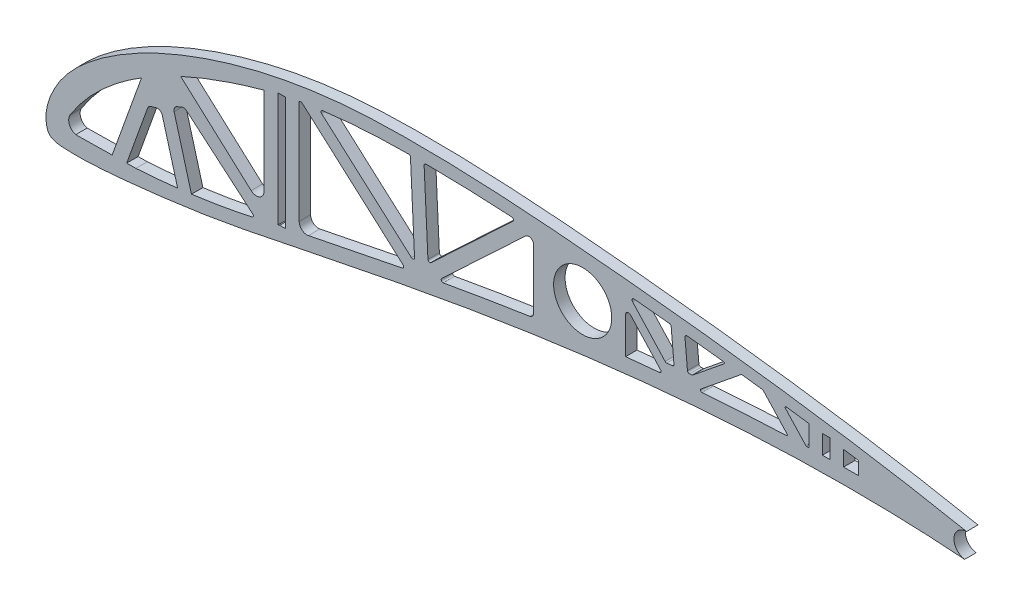
from build123d import *

# Parameters (mm, degrees)
BOSS_EXTRUDE1_DEPTH = 2.999994
CUT_EXTRUDE1_DEPTH  = 442.509045432


with BuildPart() as part:
    # Sketch5 → Boss-Extrude1 (new body)
    with BuildSketch(Plane.XY):
        with BuildLine():
            ThreePointArc((421.359482724, 115.899645077), (418.060296537, 112.846693401), (420.848691157, 109.321073047))
            add(Edge.make_bspline(
                [(421.359482724, 115.899645077), (419.422939988, 116.284255342), (414.228556348, 117.289659143), (405.625902382, 118.850738255), (395.429831787, 120.551182356), (384.871112955, 122.177527554), (374.010769017, 123.70780581), (362.918840653, 125.146254204), (351.666446869, 126.481244094), (340.335006422, 127.709125141), (329.014820288, 128.840925514), (317.799901282, 129.845464185), (306.781783127, 130.702319985), (296.038637416, 131.355846156), (285.63235588, 131.76410293), (275.621652199, 131.864898577), (266.057112324, 131.708674412), (256.959041301, 131.115735932), (248.324428285, 130.048336472), (240.116869122, 128.593792257), (232.33442802, 126.748456413), (224.983805263, 124.608842409), (218.095726105, 122.211484694), (211.698881932, 119.61063358), (205.83305294, 116.820298862), (200.516416551, 113.895751123), (195.777665531, 110.869813311), (191.646222096, 107.78301331), (188.122929029, 104.699592527), (185.259935993, 101.587133278), (183.070700685, 98.472434373), (181.463453667, 95.449399831), (180.446050206, 92.586133024), (179.978667249, 89.949794547), (180.106270294, 87.727234024), (180.706736606, 85.695404682), (182.848852115, 84.712029214), (185.712266238, 84.609143082), (189.628630725, 84.525044197), (194.54846024, 84.804700692), (200.418474116, 85.275220574), (207.172506559, 85.992641777), (214.741551325, 86.941862316), (223.08839502, 88.140518381), (232.206318165, 89.780943478), (242.140449319, 91.817484873), (252.943553217, 94.033776805), (264.563402805, 96.376783078), (276.928065981, 98.754869756), (289.947648613, 101.083910875), (303.52189838, 103.290712061), (317.534609223, 105.299544897), (331.860269168, 107.055783674), (346.364310587, 108.487545698), (360.901451873, 109.560734642), (375.320165522, 110.238690692), (389.464322211, 110.492986766), (403.176168896, 110.317339134), (413.589267576, 109.841826439), (419.410763405, 109.431625018), (420.848691157, 109.321073047)],
                knots=[0.106715339, 0.106715339, 0.106715339, 0.106715339, 0.115990637, 0.131570422, 0.147788379, 0.164550917, 0.181757895, 0.199311955, 0.217095072, 0.234990228, 0.252856883, 0.270540594, 0.287886779, 0.304773438, 0.321101419, 0.336806063, 0.351800033, 0.366031063, 0.379615675, 0.392652963, 0.405170359, 0.417171919, 0.428603517, 0.439418959, 0.449596586, 0.459102079, 0.467907878, 0.475988301, 0.483308969, 0.489874508, 0.49580325, 0.501149412, 0.505903073, 0.510046769, 0.513579311, 0.516446927, 0.519350053, 0.523823355, 0.529973794, 0.537715654, 0.546967844, 0.557637367, 0.569620481, 0.582804124, 0.597246961, 0.613135037, 0.6304436, 0.649056124, 0.668822257, 0.689594964, 0.711189651, 0.733426689, 0.756094118, 0.778988554, 0.801889683, 0.824566598, 0.846792285, 0.868338291, 0.888978163, 0.895752992, 0.895752992, 0.895752992, 0.895752992], degree=3))
        make_face()
    extrude(amount=BOSS_EXTRUDE1_DEPTH)

    # Sketch7 → Cut-Extrude1 (cut, through all)
    with BuildSketch(Plane.XY.offset(2.999994)):
        with BuildLine():
            Line((213.642245402, 107.343064385), (218.190281824, 90.885724053))
            add(Edge.make_bspline(
                [(218.190281824, 90.885724053), (223.54842124, 91.601696012), (228.883768537, 92.533835132), (234.204579075, 93.680780501)],
                knots=[0.606867129, 0.606867129, 0.606867129, 0.606867129, 0.897544008, 0.897544008, 0.897544008, 0.897544008], degree=3))
            ThreePointArc((234.204579075, 93.680780501), (234.412432502, 94.053617139), (234.243207207, 94.445501056))
            Line((234.243207207, 94.445501056), (232.954197496, 95.542398431))
            Line((232.954197496, 95.542398431), (216.91552149, 109.190690951))
            ThreePointArc((216.91552149, 109.190690951), (216.275180402, 109.480275071), (215.578889972, 109.385010658))
            Line((215.578889972, 109.385010658), (214.352783449, 108.842876386))
            ThreePointArc((214.352783449, 108.842876386), (213.718644606, 108.225085355), (213.642245402, 107.343064385))
        make_face()
        with BuildLine():
            Line((201.19969266, 89.439567272), (203.633260847, 89.477154123))
            add(Edge.make_bspline(
                [(203.633260847, 89.477154123), (207.290031523, 89.696995537), (210.932967113, 90.016308369), (214.564622737, 90.434671401)],
                knots=[0.344744583, 0.344744583, 0.344744583, 0.344744583, 0.541368109, 0.541368109, 0.541368109, 0.541368109], degree=3))
            Line((214.564622737, 90.434671401), (210.53930593, 105.000519713))
            ThreePointArc((210.53930593, 105.000519713), (209.941564564, 105.767018379), (208.976901187, 105.88634781))
            Line((208.976901187, 105.88634781), (207.552098501, 105.492599223))
            ThreePointArc((207.552098501, 105.492599223), (207.027161953, 105.200009948), (206.695522088, 104.698829479))
            Line((206.695522088, 104.698829479), (201.19969266, 89.439567272))
        make_face()
        with BuildLine():
            Line((187.845211094, 89.23330516), (197.398942173, 89.38086407))
            Line((197.398942173, 89.38086407), (205.097671742, 110.756515317))
            add(Edge.make_bspline(
                [(186.396762558, 93.028007776), (190.627378034, 99.747219914), (196.861014429, 105.656722428), (205.097671742, 110.756515317)],
                knots=[0.078395606, 0.078395606, 0.078395606, 0.078395606, 0.504900168, 0.504900168, 0.504900168, 0.504900168], degree=3))
            ThreePointArc((186.396762558, 93.028007776), (186.173187964, 90.768879008), (187.845211094, 89.23330516))
        make_face()
        with BuildLine():
            add(Edge.make_bspline(
                [(215.356082941, 116.219932627), (221.777396102, 119.170569876), (229.065901923, 121.770649506), (237.221600403, 124.020171518)],
                knots=[0.666985205, 0.666985205, 0.666985205, 0.666985205, 0.947618203, 0.947618203, 0.947618203, 0.947618203], degree=3))
            Line((215.356082941, 116.219932627), (233.827637739, 99.537260179))
            ThreePointArc((233.827637739, 99.537260179), (236.014680965, 99.188315304), (237.221600403, 101.045266049))
            Line((237.221600403, 101.045266049), (237.221600403, 110.844253218))
            Line((237.221600403, 110.844253218), (237.221600403, 124.020171518))
        make_face()
        with BuildLine():
            add(Edge.make_bspline(
                [(249.049624439, 96.863139544), (252.442739344, 97.564667818), (260.557528515, 99.233868378), (268.702010572, 100.849804318), (273.448389189, 101.758431722)],
                knots=[0.624761538, 0.624761538, 0.624761538, 0.624761538, 0.641030411, 0.66365445, 0.66365445, 0.66365445, 0.66365445], degree=3))
            ThreePointArc((273.448389189, 101.758431722), (273.807397327, 102.109530386), (273.66007194, 102.58958491))
            Line((273.66007194, 102.58958491), (247.219908667, 126.055673912))
            ThreePointArc((247.219908667, 126.055673912), (247.030859164, 126.159124951), (246.815628716, 126.169973273))
            add(Edge.make_bspline(
                [(246.815628716, 126.169973273), (246.845447128, 126.175845694), (246.875270404, 126.181690112)],
                knots=[0, 0, 0, 0.010414543, 0.010414543, 0.010414543], degree=2))
            add(Edge.make_bspline(
                [(246.875270404, 126.181690112), (246.723964627, 126.155930192), (246.572700448, 126.129938085), (246.421478436, 126.103713596)],
                knots=[1.383595085, 1.383595085, 1.383595085, 1.383595085, 1.38433327, 1.38433327, 1.38433327, 1.38433327], degree=3))
            Line((246.421478436, 126.103713596), (246.421478436, 110.844253218))
            Line((246.421478436, 110.844253218), (246.421478436, 98.814819418))
            ThreePointArc((246.421478436, 98.814819418), (247.17048458, 97.239081253), (248.865327613, 96.824994235))
            Line((248.865327613, 96.824994235), (249.049624439, 96.863139544))
        make_face()
        with BuildLine():
            add(Edge.make_bspline(
                [(275.105968573, 128.45257632), (275.11655477, 128.453053472), (275.127141067, 128.453526281)],
                knots=[0, 0, 0, 0.004656307, 0.004656307, 0.004656307], degree=2))
            add(Edge.make_bspline(
                [(275.127141067, 128.453526281), (273.34144729, 128.438772526), (268.404924317, 128.352568235), (260.863944067, 127.980339584), (255.124382119, 127.37601576), (252.500146594, 127.030357334)],
                knots=[1.338276177, 1.338276177, 1.338276177, 1.338276177, 1.346756394, 1.36175293, 1.374476832, 1.374476832, 1.374476832, 1.374476832], degree=3))
            add(Edge.make_bspline(
                [(252.500146594, 127.030357334), (252.543459431, 127.03496862), (252.586782222, 127.039522603)],
                knots=[0.985102215, 0.985102215, 0.985102215, 1, 1, 1], degree=2))
            ThreePointArc((252.586782222, 127.039522603), (252.188728833, 126.702364074), (252.329847672, 126.20016108))
            Line((252.329847672, 126.20016108), (275.859212135, 105.317454912))
            ThreePointArc((275.859212135, 105.317454912), (276.387915993, 105.243096607), (276.661603259, 105.701520217))
            Line((276.661603259, 105.701520217), (275.592459651, 127.993116549))
            ThreePointArc((275.592459651, 127.993116549), (275.441776747, 128.320854789), (275.105968573, 128.45257632))
        make_face()
        with BuildLine():
            add(Edge.make_bspline(
                [(284.433118157, 103.79717245), (291.885125519, 105.134265759), (299.357322284, 106.377889162), (306.849191388, 107.507290597)],
                knots=[0.681083789, 0.681083789, 0.681083789, 0.681083789, 0.716508208, 0.716508208, 0.716508208, 0.716508208], degree=3))
            ThreePointArc((306.849191388, 107.507290597), (307.592835311, 107.944345624), (307.885757901, 108.755653047))
            Line((307.885757901, 108.755653047), (307.885757901, 124.244115659))
            ThreePointArc((307.885757901, 124.244115659), (307.12037682, 125.409559671), (305.746766174, 125.170265419))
            Line((305.746766174, 125.170265419), (283.807657856, 104.585145779))
            ThreePointArc((283.807657856, 104.585145779), (283.699144608, 104.032164954), (284.188839864, 103.753307512))
            add(Edge.make_bspline(
                [(284.188839864, 103.753307512), (284.27026355, 103.7679403), (284.351689648, 103.782561955), (284.433118157, 103.79717245)],
                knots=[0.680696704, 0.680696704, 0.680696704, 0.680696704, 0.681083789, 0.681083789, 0.681083789, 0.681083789], degree=3))
        make_face()
        with BuildLine():
            ThreePointArc((320.624820706, 125.506693107), (313.11750772, 117.775648433), (320.848552394, 110.268335448))
            Line((320.848552394, 110.268335448), (320.624820706, 125.506693107))
        make_face()
        with BuildLine():
            Line((320.624820706, 125.506693107), (320.848552394, 110.268335448))
            ThreePointArc((320.848552394, 110.268335448), (326.164246671, 112.539057385), (328.35668655, 117.887514278))
            ThreePointArc((328.35668655, 117.887514278), (326.085143442, 123.315074398), (320.624820706, 125.506693107))
        make_face()
        Polygon((383.566995919, 114.331542636), (384.627167554, 114.331542636), (384.627167554, 119.265038759), (383.566995919, 119.265038759), (383.566995919, 119.2637314), (383.566995919, 114.339572873), align=None)
        Polygon((384.627167554, 119.265038759), (384.627167554, 114.331542636), (385.565975919, 114.331542636), (385.565975919, 114.372815175), (385.565975919, 118.974143683), (385.565975919, 119.265038759), align=None)
        with BuildLine():
            Line((389.121975919, 118.447261821), (389.121975919, 114.410871992))
            add(Edge.make_bspline(
                [(389.121975919, 114.410871992), (390.433018617, 114.41987529), (391.744014925, 114.423279661), (393.054902007, 114.420960163)],
                knots=[0.845101816, 0.845101816, 0.845101816, 0.845101816, 0.851218019, 0.851218019, 0.851218019, 0.851218019], degree=3))
            Line((393.054902007, 114.420960163), (393.054902007, 117.846602718))
            add(Edge.make_bspline(
                [(393.054902007, 117.846602718), (391.74434774, 118.049956082), (390.43337176, 118.250146172), (389.121975919, 118.447261821)],
                knots=[1.151801417, 1.151801417, 1.151801417, 1.151801417, 1.158055462, 1.158055462, 1.158055462, 1.158055462], degree=3))
        make_face()
        with BuildLine():
            Line((380.010995919, 114.25972434), (380.010995919, 119.755546834))
            Line((380.010995919, 119.755546834), (374.092164712, 120.574155535))
            ThreePointArc((374.092164712, 120.574155535), (373.833291415, 120.439448342), (373.871957259, 120.150196957))
            Line((373.871957259, 120.150196957), (377.270153888, 116.464450751))
            Line((377.270153888, 116.464450751), (379.241831588, 114.325933061))
            ThreePointArc((379.241831588, 114.325933061), (379.325985284, 114.265744824), (379.42716036, 114.244109844))
            add(Edge.make_bspline(
                [(379.42716036, 114.244109844), (379.621769891, 114.249431421), (379.816381812, 114.254636389), (380.010995919, 114.25972434)],
                knots=[0.830025766, 0.830025766, 0.830025766, 0.830025766, 0.830933754, 0.830933754, 0.830933754, 0.830933754], degree=3))
        make_face()
        with BuildLine():
            ThreePointArc((351.747100073, 113.438015367), (351.63050976, 113.008769286), (352.000259883, 112.761523769))
            add(Edge.make_bspline(
                [(352.000259883, 112.761523769), (352.822931149, 112.826809284), (360.198086878, 113.396147946), (367.589417634, 113.822218386), (374.160913285, 114.071913915)],
                knots=[0.787312697, 0.787312697, 0.787312697, 0.787312697, 0.791164416, 0.821834402, 0.821834402, 0.821834402, 0.821834402], degree=3))
            ThreePointArc((374.160913285, 114.071913915), (374.374065419, 114.233978531), (374.323588583, 114.496944044))
            Line((374.323588583, 114.496944044), (368.05266997, 121.298497047))
            ThreePointArc((368.05266997, 121.298497047), (367.982242518, 121.352127132), (367.897687345, 121.378330848))
            Line((367.897687345, 121.378330848), (362.471530997, 122.050232931))
            ThreePointArc((362.471530997, 122.050232931), (362.370231877, 122.042301185), (362.280147016, 121.995299674))
            Line((362.280147016, 121.995299674), (351.747100073, 113.438015367))
        make_face()
        with BuildLine():
            Line((349.614846163, 115.545288732), (357.775068556, 122.17483699))
            ThreePointArc((357.775068556, 122.17483699), (357.858798012, 122.44292309), (357.644333305, 122.624267151))
            Line((357.644333305, 122.624267151), (348.109029828, 123.695392165))
            ThreePointArc((348.109029828, 123.695392165), (347.698625781, 123.55285671), (347.548498625, 123.145168503))
            Line((347.548498625, 123.145168503), (348.200324402, 115.841910825))
            ThreePointArc((348.200324402, 115.841910825), (348.380458132, 115.497349901), (348.751473281, 115.381082318))
            Line((348.751473281, 115.381082318), (349.339683702, 115.433580905))
            ThreePointArc((349.339683702, 115.433580905), (349.485610106, 115.468878707), (349.614846163, 115.545288732))
        make_face()
        with BuildLine():
            Line((334.235834806, 125.11502675), (343.476739036, 124.187184762))
            ThreePointArc((343.476739036, 124.187184762), (343.785950674, 124.038460812), (343.930079025, 123.727080548))
            Line((343.930079025, 123.727080548), (344.662026649, 115.526112892))
            ThreePointArc((344.662026649, 115.526112892), (344.545759066, 115.155097744), (344.201198142, 114.974964013))
            Line((344.201198142, 114.974964013), (342.766392787, 114.846905665))
            ThreePointArc((342.766392787, 114.846905665), (342.538253947, 114.878992668), (342.347748953, 115.008548653))
            Line((342.347748953, 115.008548653), (333.813414749, 124.265043598))
            ThreePointArc((333.813414749, 124.265043598), (333.731980198, 124.835472103), (334.235834806, 125.11502675))
        make_face()
        with BuildLine():
            Line((331.985450667, 110.906292758), (340.695348226, 111.754233714))
            add(Edge.make_bspline(
                [(340.695348226, 111.754233714), (340.795495171, 111.764117028), (340.895645267, 111.773975561), (340.995798511, 111.783809273)],
                knots=[0.769649341, 0.769649341, 0.769649341, 0.769649341, 0.770119312, 0.770119312, 0.770119312, 0.770119312], degree=3))
            ThreePointArc((340.995798511, 111.783809273), (341.30197354, 112.032736795), (341.223386455, 112.41943064))
            Line((341.223386455, 112.41943064), (333.307676139, 121.004954801))
            ThreePointArc((333.307676139, 121.004954801), (332.47018528, 121.198202336), (331.985450667, 120.488436244))
            Line((331.985450667, 120.488436244), (331.985450667, 110.906292758))
        make_face()
        with BuildLine():
            add(Edge.make_bspline(
                [(302.13405131, 127.697044383), (301.982270865, 127.706592173), (301.830484655, 127.71602075)],
                knots=[0, 0, 0, 0.013524704, 0.013524704, 0.013524704], degree=2))
            add(Edge.make_bspline(
                [(301.830484655, 127.71602075), (300.626307258, 127.785890353), (293.547973109, 128.172496894), (286.480976257, 128.402429627), (280.615166159, 128.451424914)],
                knots=[1.296063531, 1.296063531, 1.296063531, 1.296063531, 1.301766784, 1.329595487, 1.329595487, 1.329595487, 1.329595487], degree=3))
            add(Edge.make_bspline(
                [(280.615166159, 128.451424914), (280.136421065, 128.454911493), (279.657618929, 128.457218383)],
                knots=[0.957454834, 0.957454834, 0.957454834, 1, 1, 1], degree=2))
            ThreePointArc((279.657618929, 128.457218383), (279.306132054, 128.30879696), (279.172274298, 127.9515099))
            Line((279.172274298, 127.9515099), (280.173975227, 107.066090406))
            ThreePointArc((280.173975227, 107.066090406), (280.474932203, 106.641874085), (280.986237969, 106.737273253))
            Line((280.986237969, 106.737273253), (302.436089385, 126.863330849))
            ThreePointArc((302.436089385, 126.863330849), (302.55961411, 127.379649441), (302.13405131, 127.697044383))
        make_face()
        with BuildLine():
            Line((240.879677534, 95.395691155), (240.879677534, 95.270472236))
            add(Edge.make_bspline(
                [(240.879677534, 95.270472236), (241.027799552, 95.312209998), (241.175918277, 95.353949805), (241.324034085, 95.395691156)],
                knots=[0.612716824, 0.612716824, 0.612716824, 0.612716824, 0.613439282, 0.613439282, 0.613439282, 0.613439282], degree=3))
            Line((241.324034085, 95.395691156), (242.878657534, 95.395691156))
            Line((242.878657534, 95.395691156), (242.878657534, 95.584871993))
            Line((242.878657534, 95.584871993), (242.878657534, 110.844253218))
            Line((242.878657534, 110.844253218), (242.878657534, 125.243190289))
            Line((242.878657534, 125.243190289), (241.879167534, 125.243190289))
            Line((241.879167534, 125.243190289), (240.879677534, 125.243190289))
            Line((240.879677534, 125.243190289), (240.879677534, 124.990811264))
            Line((240.879677534, 124.990811264), (240.879677534, 110.844253218))
            Line((240.879677534, 110.844253218), (240.879677534, 95.395691155))
        make_face()
    extrude(amount=-CUT_EXTRUDE1_DEPTH, mode=Mode.SUBTRACT)


solid = part.part
